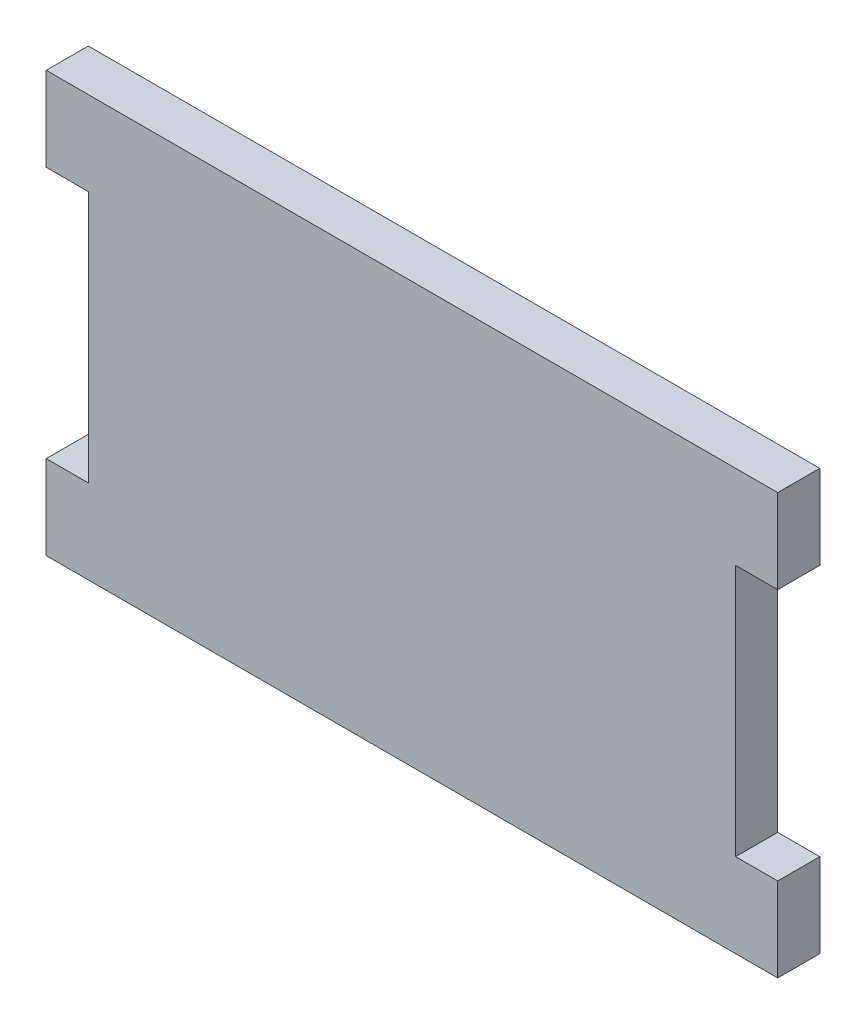
from build123d import *

# Parameters (mm, degrees)
BOSS_EXTRUDE1_DEPTH = 5


with BuildPart() as part:
    # Sketch1 → Boss-Extrude1 (new body)
    with BuildSketch(Plane.XY):
        Polygon((43.5, -15), (43.5, -25), (-43.5, -25), (-43.5, -15), (-38.5, -15), (-38.5, 15), (-43.5, 15), (-43.5, 25), (43.5, 25), (43.5, 15), (38.5, 15), (38.5, -15), align=None)
    extrude(amount=BOSS_EXTRUDE1_DEPTH)


solid = part.part
